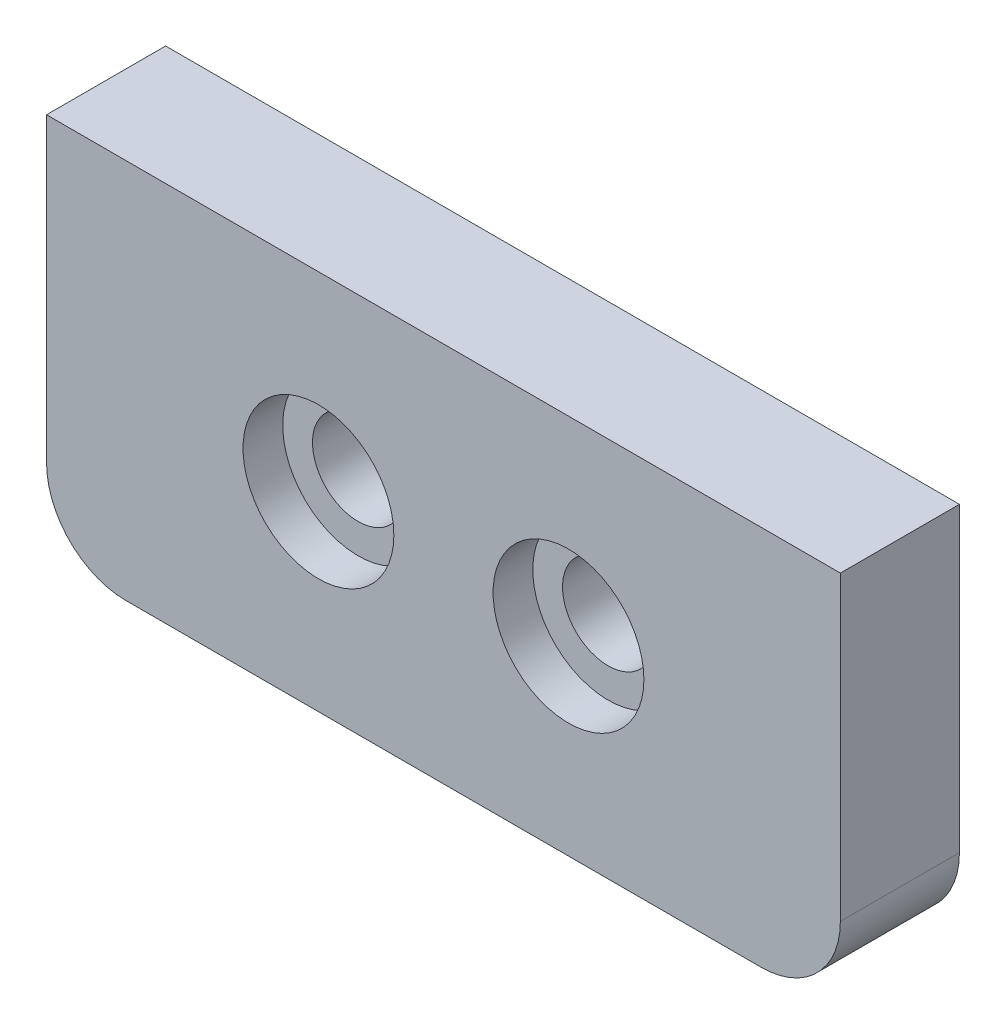
from build123d import *

# Parameters (mm, degrees)
SKETCH1_W           = 20
SKETCH1_H           = 9.6
SKETCH1_R           = 1.15
BOSS_EXTRUDE1_DEPTH = 3
FILLET1_R           = 2
SKETCH2_R           = 1.9
CUT_EXTRUDE1_DEPTH  = 1


with BuildPart() as part:
    # Sketch1 → Boss-Extrude1 (new body)
    with BuildSketch(Plane.XY):
        with Locations((10, 4.8)):
            Rectangle(SKETCH1_W, SKETCH1_H)
        with Locations((6.85, 4.8)):
            Circle(SKETCH1_R, mode=Mode.SUBTRACT)
        with Locations((13.15, 4.8)):
            Circle(SKETCH1_R, mode=Mode.SUBTRACT)
    extrude(amount=BOSS_EXTRUDE1_DEPTH)

    # Fillet1
    fillet1_edges = [part.edges().sort_by_distance(p)[0] for p in [
        (20, 0, 1.5),
        (0, 0, 1.5),
    ]]
    fillet(fillet1_edges, radius=FILLET1_R)

    # Sketch2 → Cut-Extrude1 (cut)
    with BuildSketch(Plane.XY.offset(3)):
        with Locations((6.85, 4.8)):
            Circle(SKETCH2_R)
        with Locations((13.15, 4.8)):
            Circle(SKETCH2_R)
    extrude(amount=-CUT_EXTRUDE1_DEPTH, mode=Mode.SUBTRACT)


solid = part.part
